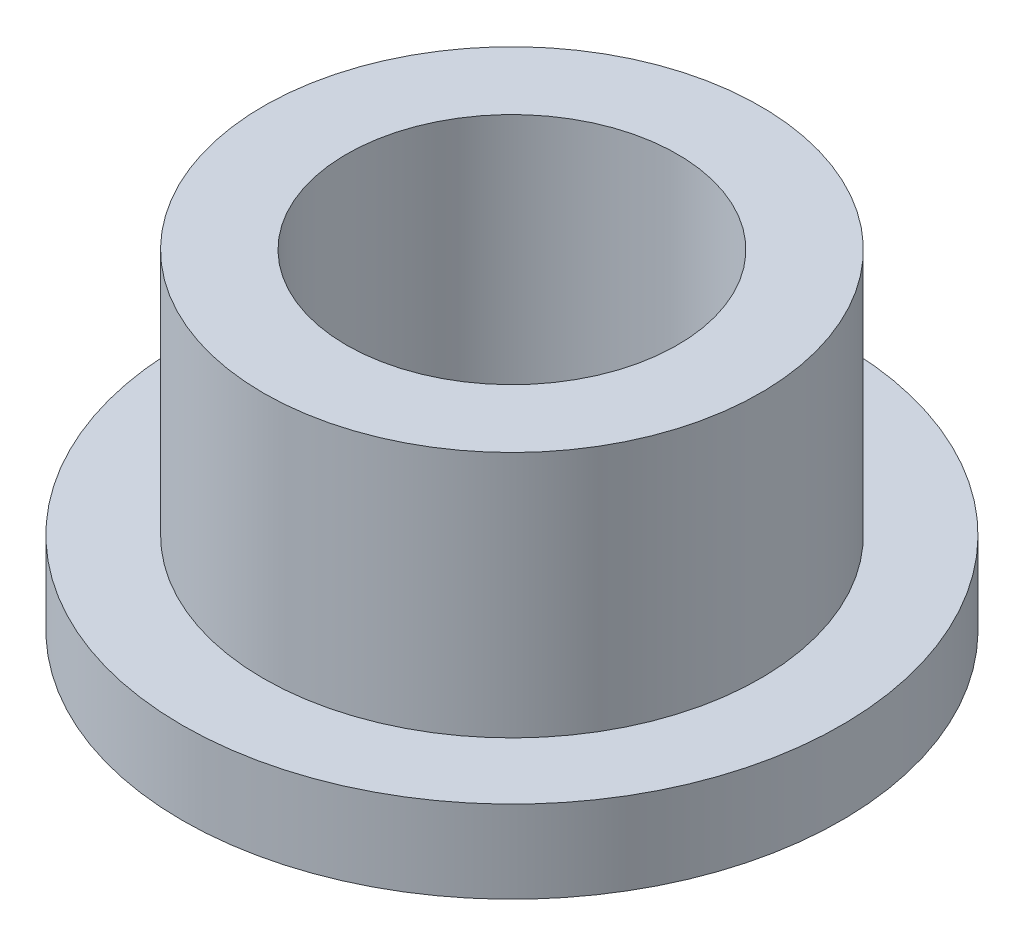
from build123d import *

# Parameters (mm, degrees)
SKETCH2_R           = 4.7879
SKETCH2_R_2         = 3.1877
BOSS_EXTRUDE1_DEPTH = 6.35
SKETCH3_R           = 6.35
SKETCH3_R_2         = 4.7879
BOSS_EXTRUDE2_DEPTH = 1.5875


with BuildPart() as part:
    # Sketch2 → Boss-Extrude1 (new body)
    with BuildSketch(Plane(origin=(0, 0, 0), x_dir=(1, 0, 0), z_dir=(0, 1, 0))):
        Circle(SKETCH2_R)
        Circle(SKETCH2_R_2, mode=Mode.SUBTRACT)
    extrude(amount=BOSS_EXTRUDE1_DEPTH)

    # Sketch3 → Boss-Extrude2 (add)
    with BuildSketch(Plane(origin=(0, 0, 0), x_dir=(1, 0, 0), z_dir=(0, 1, 0))):
        Circle(SKETCH3_R)
        Circle(SKETCH3_R_2, mode=Mode.SUBTRACT)
    extrude(amount=BOSS_EXTRUDE2_DEPTH)


solid = part.part
